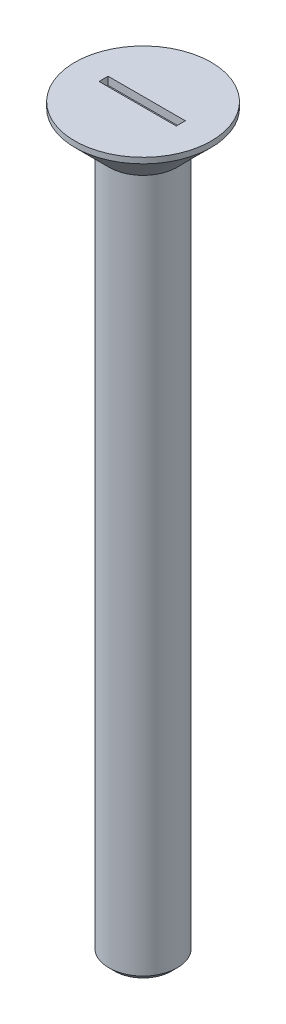
from build123d import *

# Parameters (mm, degrees)
SKETCH_2_W          = 6.792543124
SKETCH_2_H          = 0.8
CUT_EXTRUDE_1_DEPTH = 0.7
CHAMFER_1_SIZE      = 0.5


with BuildPart() as part:
    # 草圖1 → 旋轉1 (revolve)
    with BuildSketch(Plane.XY):
        Polygon((0, 65), (6, 65), (6, 64.5), (3, 61.5), (3, 0), (0, 0), align=None)
    revolve(axis=Axis((0, -8.5328125, 0), (0, 1, 0)))

    # 草圖2 → 除料-伸長1 (cut)
    with BuildSketch(Plane(origin=(0, 65, 0), x_dir=(-1, 0, 0), z_dir=(0, 1, 0))):
        with Locations((0.075670859, 0)):
            Rectangle(SKETCH_2_W, SKETCH_2_H)
    extrude(amount=-CUT_EXTRUDE_1_DEPTH, mode=Mode.SUBTRACT)

    # 導角1
    chamfer_1_edges = [part.edges().sort_by_distance(p)[0] for p in [
        (-3, 0, 0),
    ]]
    chamfer(chamfer_1_edges, length=CHAMFER_1_SIZE)


solid = part.part
